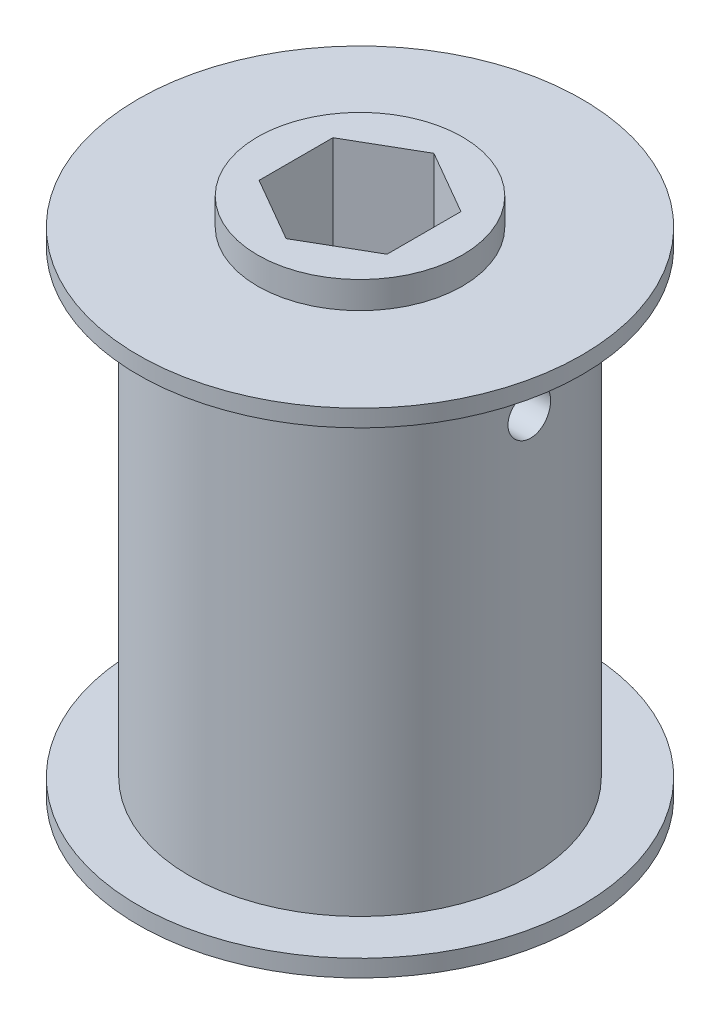
from build123d import *

# Parameters (mm, degrees)
CUT_EXTRUDE1_DEPTH      = 41.7416
SKETCH3_R               = 1.5875
CUT_EXTRUDE2_DEPTH      = 17.51
CUT_EXTRUDE2_DEPTH_BACK = 17.51


with BuildPart() as part:
    # Sketch1 → Revolve1 (revolve)
    with BuildSketch(Plane.XY):
        Polygon((-7.62, 18.3642), (-16.51, 18.3642), (-16.51, 17.0942), (-12.7, 17.0942), (-12.7, -17.0942), (-16.51, -17.0942), (-16.51, -18.3642), (-7.62, -18.3642), (-7.62, -20.3708), (0, -20.3708), (0, 20.3708), (-7.62, 20.3708), align=None)
    revolve(axis=Axis((0, 20.3708, 0), (0, -1, 0)))

    # Sketch2 → Cut-Extrude1 (cut, through all)
    with BuildSketch(Plane(origin=(0, 20.3708, 0), x_dir=(1, 0, 0), z_dir=(0, 1, 0))):
        Polygon((0, 5.499261314), (-4.7625, 2.749630657), (-4.7625, -2.749630657), (0, -5.499261314), (4.7625, -2.749630657), (4.7625, 2.749630657), align=None)
    extrude(amount=-CUT_EXTRUDE1_DEPTH, mode=Mode.SUBTRACT)

    # Sketch3 → Cut-Extrude2 (cut, two sides)
    with BuildSketch(Plane(origin=(0, 0, 0), x_dir=(0, 0, -1), z_dir=(1, 0, 0))) as cut_extrude2_sk:
        with Locations((0, 12.7)):
            Circle(SKETCH3_R)
    extrude(amount=CUT_EXTRUDE2_DEPTH, mode=Mode.SUBTRACT)
    extrude(cut_extrude2_sk.sketch, amount=-CUT_EXTRUDE2_DEPTH_BACK, mode=Mode.SUBTRACT)


solid = part.part
